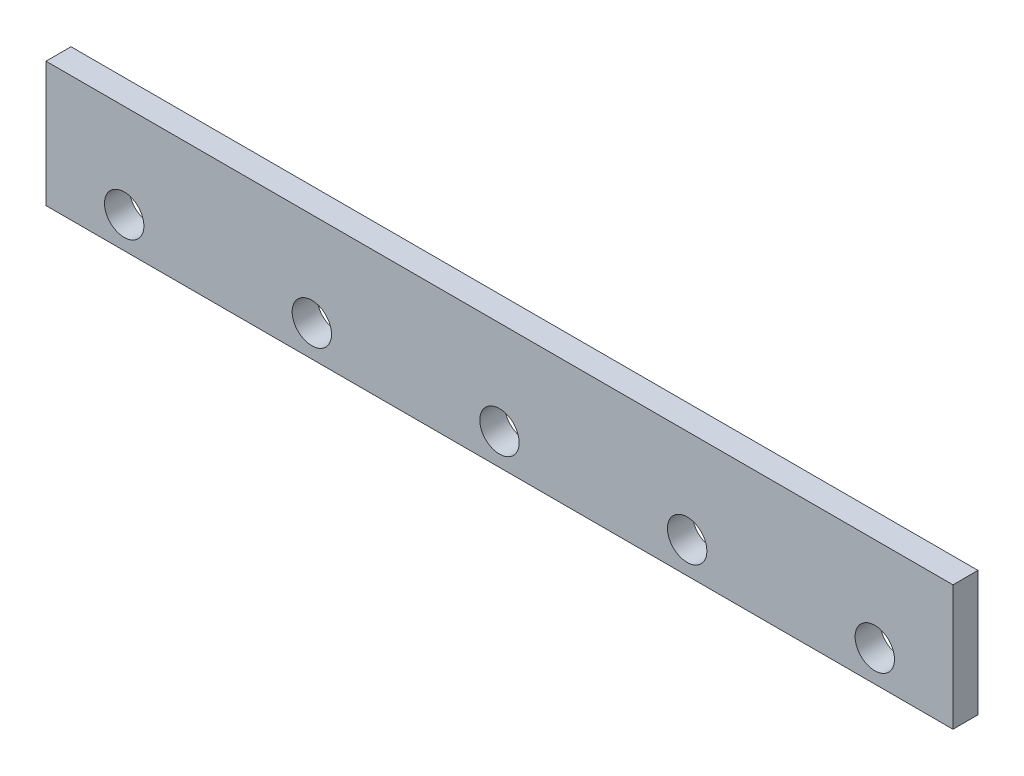
from build123d import *

# Parameters (mm, degrees)
SKETCH1_W           = 580
SKETCH1_H           = 80
SKETCH1_R           = 12.6
BOSS_EXTRUDE1_DEPTH = 16


with BuildPart() as part:
    # Sketch1 → Boss-Extrude1 (new body)
    with BuildSketch(Plane.XY):
        with Locations((290, 40)):
            Rectangle(SKETCH1_W, SKETCH1_H)
        with Locations((50, 20)):
            Circle(SKETCH1_R, mode=Mode.SUBTRACT)
        with Locations((170, 20)):
            Circle(SKETCH1_R, mode=Mode.SUBTRACT)
        with Locations((290, 20)):
            Circle(SKETCH1_R, mode=Mode.SUBTRACT)
        with Locations((410, 20)):
            Circle(SKETCH1_R, mode=Mode.SUBTRACT)
        with Locations((530, 20)):
            Circle(SKETCH1_R, mode=Mode.SUBTRACT)
    extrude(amount=BOSS_EXTRUDE1_DEPTH)


solid = part.part
